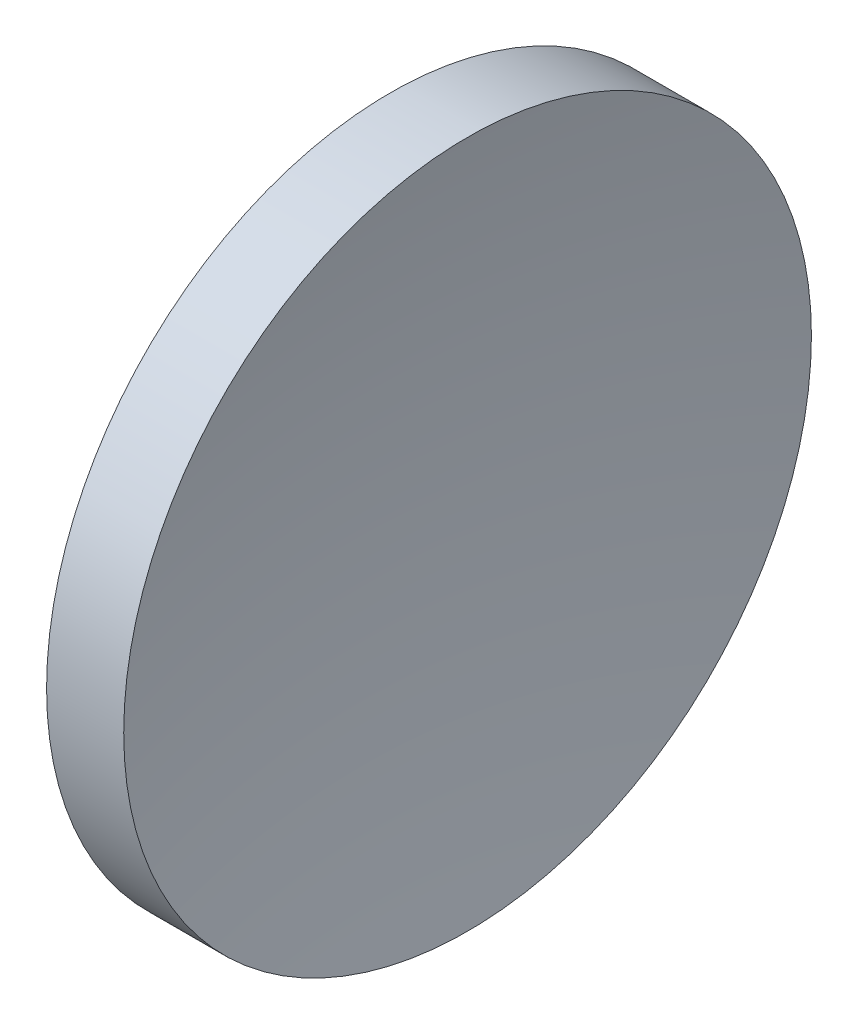
from build123d import *


with BuildPart() as part:
    # 草图1 → 旋转1 (revolve)
    with BuildSketch(Plane.XY, mode=Mode.PRIVATE) as revolve_1_sk:
        with BuildLine():
            Line((113.911931674, 65.155630457), (113.911931674, 85.155630457))
            Line((113.911931674, 85.155630457), (118.398576451, 85.155630457))
            ThreePointArc((118.398576451, 85.155630457), (116.917593738, 75.204070849), (116.411931674, 65.155630457))
            Line((116.411931674, 65.155630457), (113.911931674, 65.155630457))
        make_face()
    revolve(revolve_1_sk.sketch.rotate(Axis((105.621837124, 65.155630457, 0), (1, 0, 0)), 90), axis=Axis((105.621837124, 65.155630457, 0), (1, 0, 0)))  # turned: the seam where the file's is


solid = part.part
